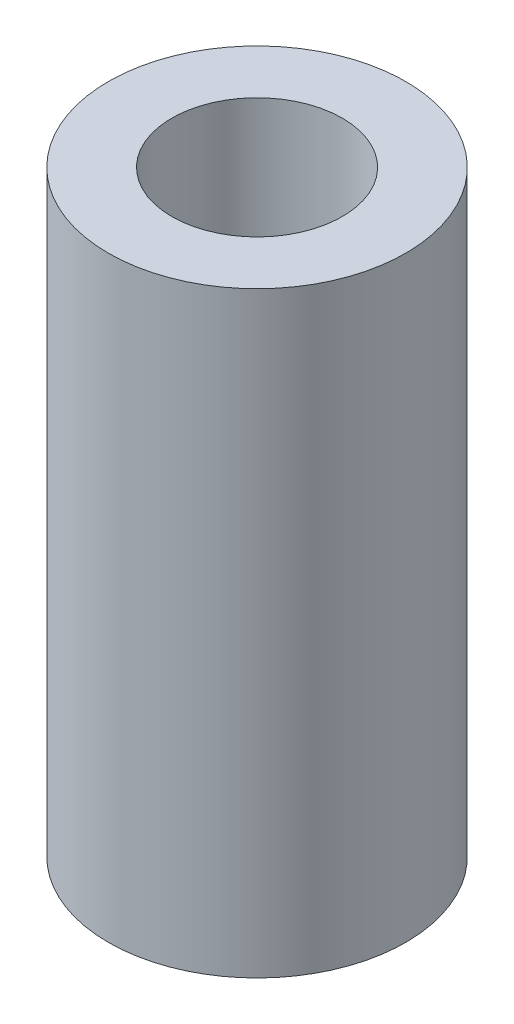
from build123d import *

# Parameters (mm, degrees)
SKETCH1_R           = 6.975
SKETCH1_R_2         = 4
BOSS_EXTRUDE1_DEPTH = 14


with BuildPart() as part:
    # Sketch1 → Boss-Extrude1 (new body, symmetric)
    with BuildSketch(Plane(origin=(0, 0, 0), x_dir=(1, 0, 0), z_dir=(0, 1, 0))):
        Circle(SKETCH1_R)
        Circle(SKETCH1_R_2, mode=Mode.SUBTRACT)
    extrude(amount=BOSS_EXTRUDE1_DEPTH, both=True)


solid = part.part
